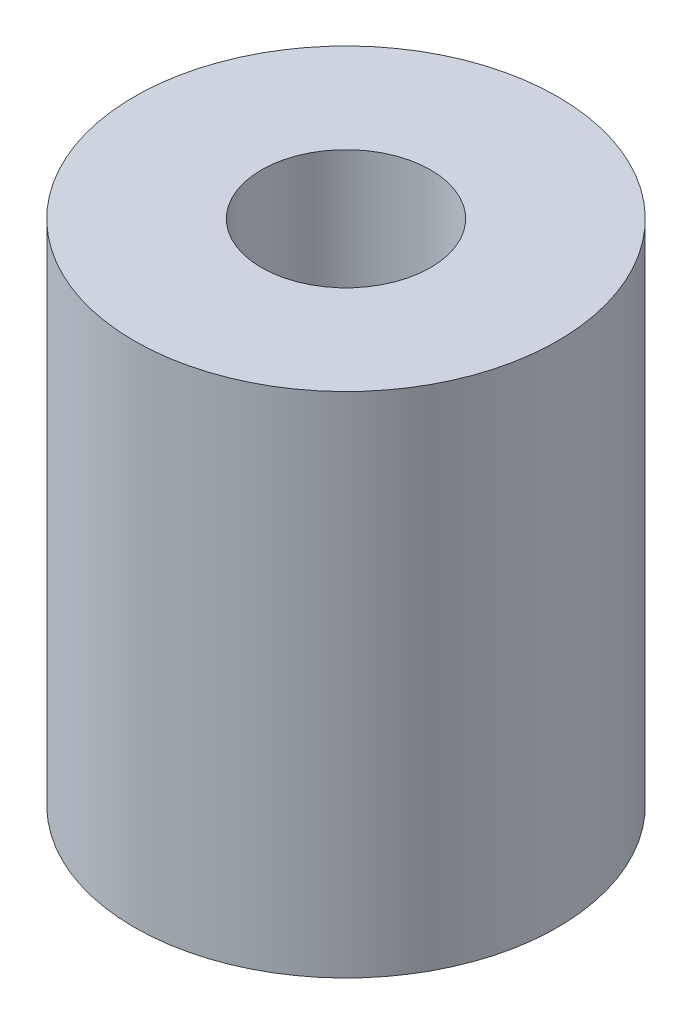
from build123d import *

# Parameters (mm, degrees)
SKETCH2_R           = 2.5
SKETCH2_R_2         = 1
BOSS_EXTRUDE1_DEPTH = 6


with BuildPart() as part:
    # Sketch2 → Boss-Extrude1 (new body)
    with BuildSketch(Plane(origin=(0, 0, 0), x_dir=(1, 0, 0), z_dir=(0, 1, 0))):
        Circle(SKETCH2_R)
        Circle(SKETCH2_R_2, mode=Mode.SUBTRACT)
    extrude(amount=BOSS_EXTRUDE1_DEPTH)


solid = part.part
